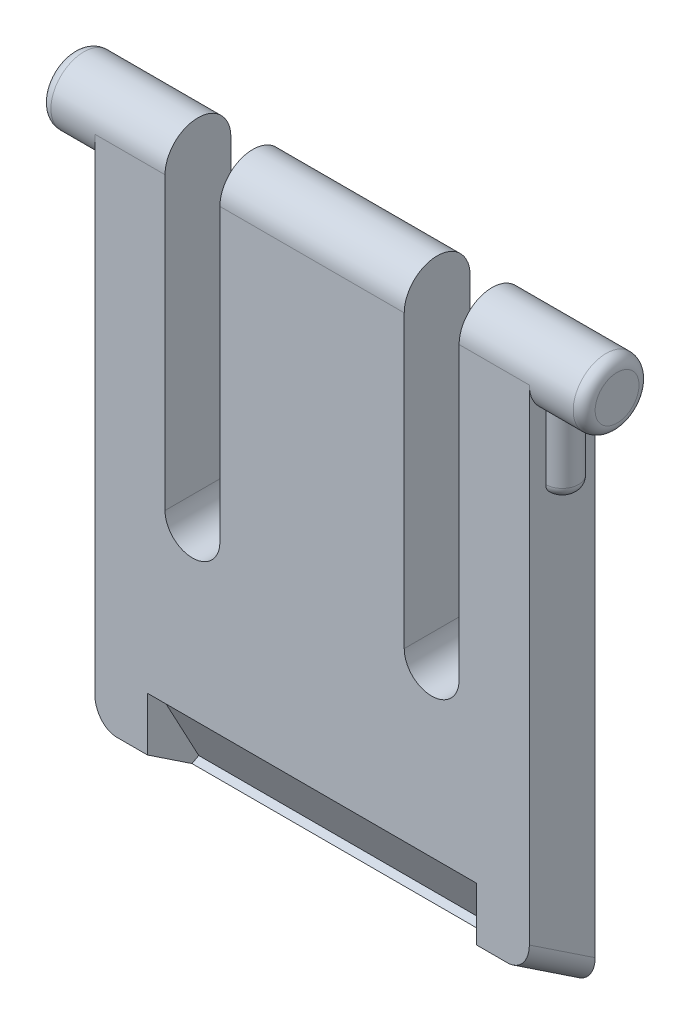
from build123d import *

# Parameters (mm, degrees)
BOSS_EXTRUDE1_DEPTH      = 3
SKETCH2_R                = 1.5
BOSS_EXTRUDE2_DEPTH      = 2.5
BOSS_EXTRUDE2_DEPTH_BACK = 22.3
SKETCH3_W                = 2.5
SKETCH3_H                = 20.733799839
CUT_EXTRUDE1_DEPTH       = 4
CUT_EXTRUDE1_DEPTH_BACK  = 1
BOSS_EXTRUDE3_START      = -0.5
BOSS_EXTRUDE3_DEPTH      = 5.8
FILLET1_R                = 0.5
FILLET1_OF_MIRROR1_R     = 0.5
CUT_EXTRUDE2_DEPTH       = 23.3000001
SKETCH8_W                = 15
SKETCH8_H                = 4.3
CUT_EXTRUDE3_DEPTH       = 1.5
FILLET2_R                = 0.5
FILLET3_R                = 1


with BuildPart() as part:
    # Sketch1 → Boss-Extrude1 (new body)
    with BuildSketch(Plane.XY):
        with BuildLine():
            Line((3.2, 25.3), (3.2, 12.05))
            ThreePointArc((3.2, 12.05), (4.45, 10.8), (5.7, 12.05))
            Line((5.7, 12.05), (5.7, 25.3))
            Line((5.7, 25.3), (14.1, 25.3))
            Line((14.1, 25.3), (14.1, 12.05))
            ThreePointArc((14.1, 12.05), (15.35, 10.8), (16.6, 12.05))
            Line((16.6, 12.05), (16.6, 25.3))
            Line((16.6, 25.3), (19.8, 25.3))
            Line((19.8, 25.3), (19.8, 0))
            Line((19.8, 0), (0, 0))
            Line((0, 0), (0, 25.3))
            Line((0, 25.3), (3.2, 25.3))
        make_face()
    extrude(amount=BOSS_EXTRUDE1_DEPTH)

    # Sketch2 → Boss-Extrude2 (add, two sides)
    with BuildSketch(Plane(origin=(19.8, 0, 0), x_dir=(0, 0, -1), z_dir=(1, 0, 0))) as boss_extrude2_sk:
        with Locations((-1.5, 25.3)):
            Circle(SKETCH2_R)
    extrude(amount=BOSS_EXTRUDE2_DEPTH)
    extrude(boss_extrude2_sk.sketch, amount=-BOSS_EXTRUDE2_DEPTH_BACK)

    # Sketch3 → Cut-Extrude1 (cut, two sides)
    with BuildSketch(Plane.XY) as cut_extrude1_sk:
        with Locations((4.45, 22.41689992)):
            Rectangle(SKETCH3_W, SKETCH3_H)
        with Locations((15.35, 22.41689992)):
            Rectangle(SKETCH3_W, SKETCH3_H)
    extrude(amount=CUT_EXTRUDE1_DEPTH, mode=Mode.SUBTRACT)
    extrude(cut_extrude1_sk.sketch, amount=-CUT_EXTRUDE1_DEPTH_BACK, mode=Mode.SUBTRACT)

    # Sketch5 → Boss-Extrude3 (add)
    with BuildSketch(Plane(origin=(0, 26.8, 0), x_dir=(1, 0, 0), z_dir=(0, 1, 0)).offset(BOSS_EXTRUDE3_START)):
        with BuildLine():
            Line((0, -0.75), (0, -2.25))
            ThreePointArc((0, -2.25), (-0.75, -1.5), (0, -0.75))
        make_face()
    boss_extrude3 = extrude(amount=-BOSS_EXTRUDE3_DEPTH)

    # Fillet1
    fillet1_edges = [part.edges().sort_by_distance(p)[0] for p in [
        (-0.75, 20.5, 1.5),
    ]]
    fillet(fillet1_edges, radius=FILLET1_R)

    # Mirror1: Boss-Extrude3 across plane
    add(boss_extrude3.mirror(Plane.ZY.offset(-9.9)))

    # Fillet1 of Mirror1
    fillet1_of_mirror1_edges = [part.edges().sort_by_distance(p)[0] for p in [
        (20.55, 20.5, 1.5),
    ]]
    fillet(fillet1_of_mirror1_edges, radius=FILLET1_OF_MIRROR1_R)

    # Sketch6 → Cut-Extrude2 (cut, through all)
    with BuildSketch(Plane.ZY):
        Polygon((0, 0), (3, 2), (3, -2.592158126), (0, -2.592158126), align=None)
    extrude(amount=-CUT_EXTRUDE2_DEPTH, mode=Mode.SUBTRACT)

    # Sketch8 → Cut-Extrude3 (cut)
    with BuildSketch(Plane(origin=(0, -0.802775638, 1.499997875), x_dir=(-1, 0, 0), z_dir=(0, 0.471858445, -0.881674321))):
        with Locations((-9.9, 3.178923977)):
            Rectangle(SKETCH8_W, SKETCH8_H)
    extrude(amount=CUT_EXTRUDE3_DEPTH, mode=Mode.SUBTRACT)

    # Fillet2
    fillet2_edges = [part.edges().sort_by_distance(p)[0] for p in [
        (-2.5, 25.3, 3),
        (22.3, 25.3, 3),
    ]]
    fillet(fillet2_edges, radius=FILLET2_R)

    # Fillet3
    fillet3_edges = [part.edges().sort_by_distance(p)[0] for p in [
        (19.8, 1, 1.5),
        (0, 1, 1.5),
    ]]
    fillet(fillet3_edges, radius=FILLET3_R)


solid = part.part
